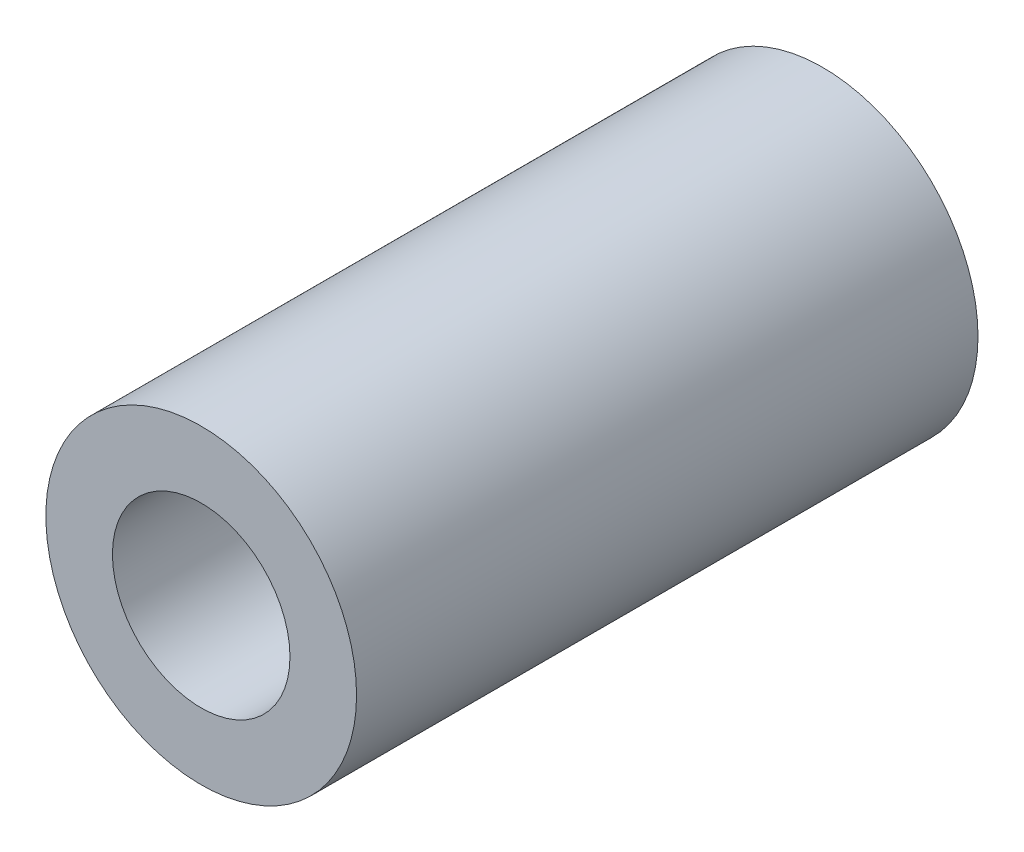
from build123d import *

# Parameters (mm, degrees)
SKETCH1_R           = 7
BOSS_EXTRUDE2_DEPTH = 28
SKETCH2_R           = 4
CUT_EXTRUDE1_DEPTH  = 29


with BuildPart() as part:
    # Sketch1 → Boss-Extrude2 (new body)
    with BuildSketch(Plane.XY):
        Circle(SKETCH1_R)
    extrude(amount=-BOSS_EXTRUDE2_DEPTH)

    # Sketch2 → Cut-Extrude1 (cut, through all)
    with BuildSketch(Plane.XY):
        Circle(SKETCH2_R)
    extrude(amount=-CUT_EXTRUDE1_DEPTH, mode=Mode.SUBTRACT)


solid = part.part
